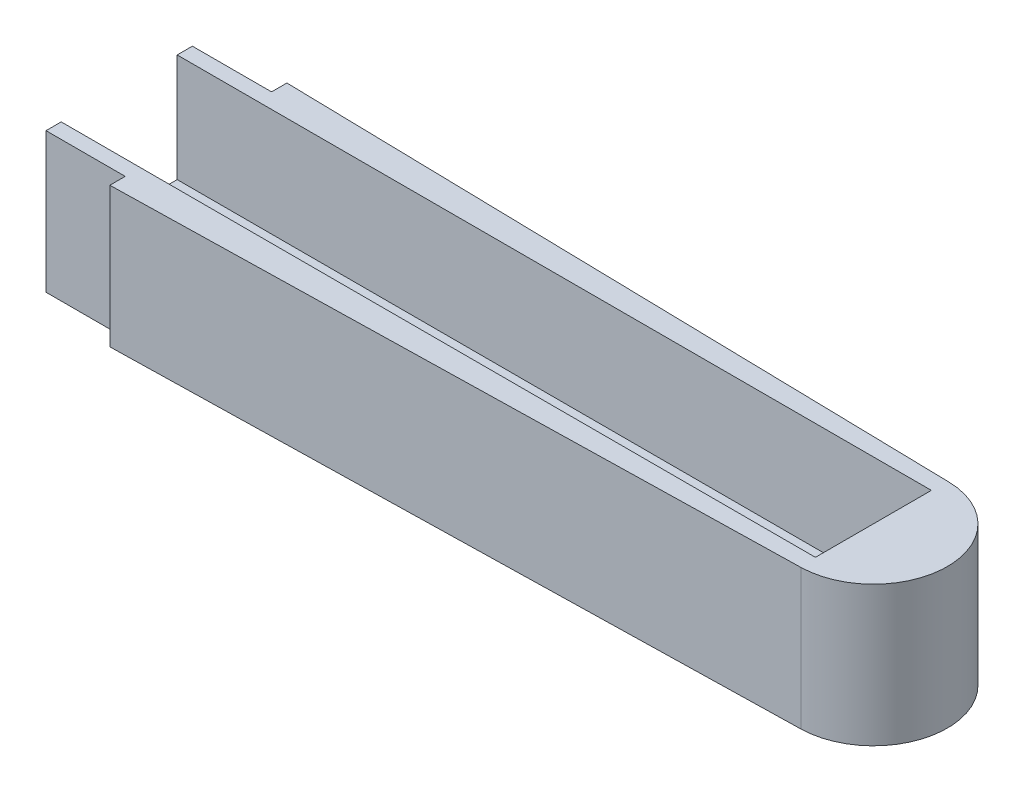
from build123d import *

# Parameters (mm, degrees)
BOSS_EXTRUDE1_DEPTH     = 17.5
SKETCH2_W               = 252
SKETCH2_H               = 14.5
CUT_EXTRUDE1_DEPTH      = 15.5
SKETCH3_R               = 13
CUT_EXTRUDE2_DEPTH      = 15.5
CUT_EXTRUDE3_REACH      = 264.265
CUT_EXTRUDE3_END_RADIUS = 13
SKETCH5_W               = 252
SKETCH5_H               = 1
BOSS_EXTRUDE2_DEPTH     = 2
SKETCH6_R               = 1
CUT_EXTRUDE4_DEPTH      = 2
CUT_EXTRUDE9_DEPTH      = 278.209870862


with BuildPart() as part:
    # Sketch1 → Boss-Extrude1 (new body)
    with BuildSketch(Plane(origin=(0, 0, 0), x_dir=(1, 0, 0), z_dir=(0, 1, 0))):
        with BuildLine():
            Line((0.323033708, 14.996521237), (267.19920412, 9.247854763))
            ThreePointArc((267.19920412, 9.247854763), (276.25, 0), (267.19920412, -9.247854763))
            Line((267.19920412, -9.247854763), (0.323033708, -14.996521237))
            ThreePointArc((0.323033708, -14.996521237), (-15, 0), (0.323033708, 14.996521237))
        make_face()
    extrude(amount=BOSS_EXTRUDE1_DEPTH)

    # Sketch2 → Cut-Extrude1 (cut)
    with BuildSketch(Plane(origin=(0, 17.5, 0), x_dir=(1, 0, 0), z_dir=(0, 1, 0))):
        with Locations((141, 0)):
            Rectangle(SKETCH2_W, SKETCH2_H)
    extrude(amount=-CUT_EXTRUDE1_DEPTH, mode=Mode.SUBTRACT)

    # Sketch3 → Cut-Extrude2 (cut)
    with BuildSketch(Plane(origin=(0, 17.5, 0), x_dir=(1, 0, 0), z_dir=(0, 1, 0))):
        with Locations(Location((0, 0, 0), (0, 0, 270))):
            Circle(SKETCH3_R)
    extrude(amount=-CUT_EXTRUDE2_DEPTH, mode=Mode.SUBTRACT)

    # Cut-Extrude3: up to this cylinder (the profile starts outside it)
    cut_extrude3_end = Plane(origin=(0, 8.125709, 0), z_dir=(0, 1, 0)) * Cylinder(CUT_EXTRUDE3_END_RADIUS, 555.53, mode=Mode.PRIVATE)
    # Sketch4 → Cut-Extrude3 (cut, up to the surface)
    with BuildSketch(Plane(origin=(15, 0, 0), x_dir=(0, 0, -1), z_dir=(1, 0, 0)), mode=Mode.PRIVATE) as cut_extrude3_sk1:
        with BuildLine():
            Line((-7.25, 2), (7.25, 2))
            Line((7.25, 2), (7.25, 8.5))
            ThreePointArc((7.25, 8.5), (5.199747468, 13.449747468), (0.25, 15.5))
            Line((0.25, 15.5), (-0.25, 15.5))
            ThreePointArc((-0.25, 15.5), (-5.199747468, 13.449747468), (-7.25, 8.5))
            Line((-7.25, 8.5), (-7.25, 2))
        make_face()
    cut_extrude3_tool1 = extrude(cut_extrude3_sk1.sketch, amount=-CUT_EXTRUDE3_REACH, mode=Mode.PRIVATE) - cut_extrude3_end
    add(cut_extrude3_tool1.solids().sort_by_distance((15, 8.125709, 0))[0], mode=Mode.SUBTRACT)

    # Sketch5 → Boss-Extrude2 (add)
    with BuildSketch(Plane(origin=(0, 2, 0), x_dir=(1, 0, 0), z_dir=(0, 1, 0))):
        with Locations((141, 6.75)):
            Rectangle(SKETCH5_W, SKETCH5_H)
        with Locations((141, -6.75)):
            Rectangle(SKETCH5_W, SKETCH5_H)
    extrude(amount=BOSS_EXTRUDE2_DEPTH)

    # Sketch6 → Cut-Extrude4 (cut)
    with BuildSketch(Plane(origin=(0, 2, 0), x_dir=(1, 0, 0), z_dir=(0, 1, 0))):
        with Locations(Location((-5.25, 9.09326674, 0), (0, 0, 270))):
            Circle(SKETCH6_R)
        with Locations(Location((-10.5, 0, 0), (0, 0, 270))):
            Circle(SKETCH6_R)
        with Locations(Location((5.25, 9.09326674, 0), (0, 0, 270))):
            Circle(SKETCH6_R)
        with Locations(Location((10.5, 0, 0), (0, 0, 270))):
            Circle(SKETCH6_R)
        with Locations(Location((5.25, -9.09326674, 0), (0, 0, 270))):
            Circle(SKETCH6_R)
        with Locations(Location((-5.25, -9.09326674, 0), (0, 0, 270))):
            Circle(SKETCH6_R)
        Polygon((0, -10), (8.660254038, -5), (8.660254038, 5), (0, 10), (-8.660254038, 5), (-8.660254038, -5), align=None)
    extrude(amount=-CUT_EXTRUDE4_DEPTH, mode=Mode.SUBTRACT)

    # Sketch14 → Cut-Extrude9 (cut, through all)
    with BuildSketch(Plane(origin=(0, 0, 0), x_dir=(1, 0, 0), z_dir=(0, 1, 0))):
        Polygon((88.5, 9.35), (78.6, 9.35), (78.6, 35), (78.4, 35), (78.4, 9.15), (88.3, 9.15), (88.3, -9.15), (78.4, -9.15), (78.4, -35), (78.6, -35), (78.6, -9.35), (88.5, -9.35), align=None)
        Polygon((172.7, 9.15), (182.6, 9.15), (182.6, 35), (182.4, 35), (182.4, 9.35), (172.5, 9.35), (172.5, 9.25), (172.5, -9.35), (182.4, -9.35), (182.4, -35), (182.6, -35), (182.6, -9.15), (172.7, -9.15), align=None)
    extrude(amount=CUT_EXTRUDE9_DEPTH, mode=Mode.SUBTRACT)


with BuildPart() as cut_extrude9_kept_piece:
    # of the separate pieces the step leaves, the one the design keeps (cut_extrude9_pieces_kept)
    add(part.part.solids().sort_by_distance((267.19920412, 0, 9.247854763))[0])


solid = cut_extrude9_kept_piece.part
